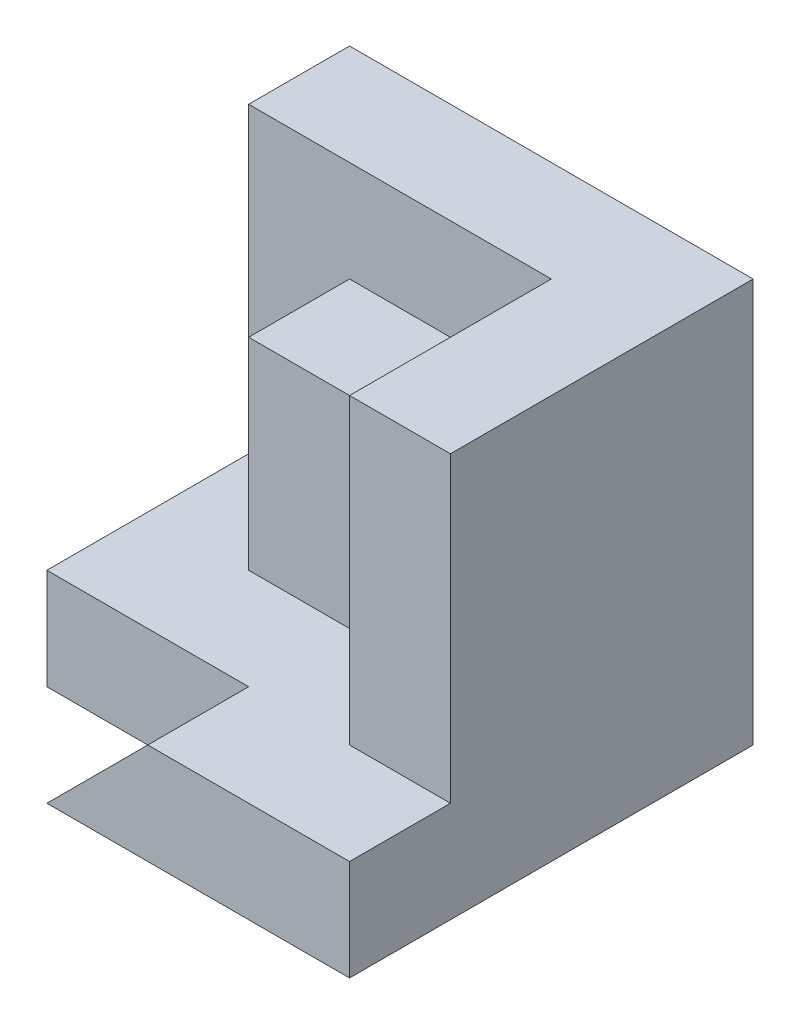
from build123d import *

# Parameters (mm, degrees)
SKETCH1_W           = 40
SKETCH1_H           = 40
BOSS_EXTRUDE1_DEPTH = 40
SKETCH2_W           = 10
SKETCH2_H           = 10
CUT_EXTRUDE1_DEPTH  = 40
SKETCH4_W           = 10
SKETCH4_H           = 30
CUT_EXTRUDE3_DEPTH  = 40
CUT_EXTRUDE4_DEPTH  = 10
CUT_EXTRUDE5_DEPTH  = 30
SKETCH7_W           = 20
SKETCH7_H           = 10
CUT_EXTRUDE6_DEPTH  = 10


with BuildPart() as part:
    # Sketch1 → Boss-Extrude1 (new body)
    with BuildSketch(Plane.XY):
        with Locations((20, 20)):
            Rectangle(SKETCH1_W, SKETCH1_H)
    extrude(amount=BOSS_EXTRUDE1_DEPTH)

    # Sketch2 → Cut-Extrude1 (cut)
    with BuildSketch(Plane(origin=(0, 40, 0), x_dir=(1, 0, 0), z_dir=(0, 1, 0))):
        with Locations((5, -35)):
            Rectangle(SKETCH2_W, SKETCH2_H)
    extrude(amount=-CUT_EXTRUDE1_DEPTH, mode=Mode.SUBTRACT)

    # Sketch4 → Cut-Extrude3 (cut)
    with BuildSketch(Plane.ZY.offset(-10)):
        with Locations((35, 25)):
            Rectangle(SKETCH4_W, SKETCH4_H)
    extrude(amount=-CUT_EXTRUDE3_DEPTH, mode=Mode.SUBTRACT)

    # Sketch5 → Cut-Extrude4 (cut)
    with BuildSketch(Plane.XY.offset(40)):
        Polygon((10, 0), (20, 10), (10, 10), align=None)
    extrude(amount=-CUT_EXTRUDE4_DEPTH, mode=Mode.SUBTRACT)

    # Sketch6 → Cut-Extrude5 (cut)
    with BuildSketch(Plane(origin=(0, 40, 0), x_dir=(1, 0, 0), z_dir=(0, 1, 0))):
        Polygon((0, -30), (20, -30), (30, -30), (30, -20), (10, -20), (10, -10), (0, -10), align=None)
    extrude(amount=-CUT_EXTRUDE5_DEPTH, mode=Mode.SUBTRACT)

    # Sketch7 → Cut-Extrude6 (cut)
    with BuildSketch(Plane.XY.offset(20)):
        with Locations((20, 35)):
            Rectangle(SKETCH7_W, SKETCH7_H)
    extrude(amount=-CUT_EXTRUDE6_DEPTH, mode=Mode.SUBTRACT)


solid = part.part
